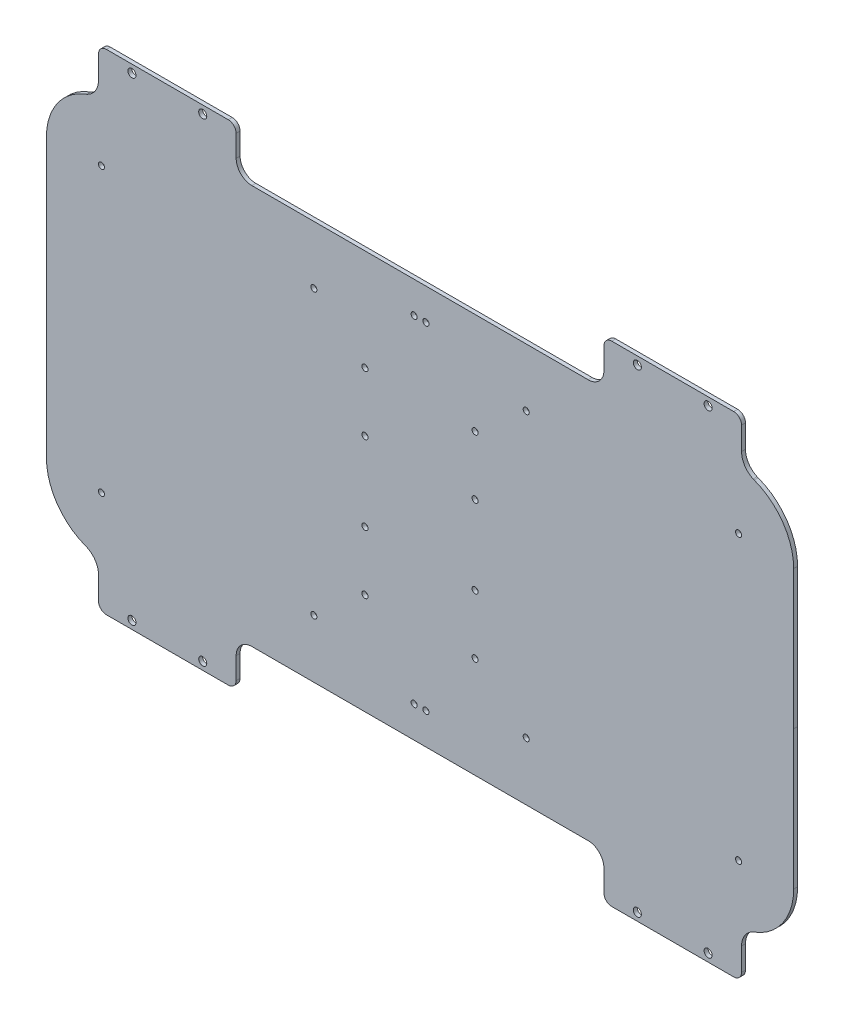
from build123d import *

# Parameters (mm, degrees)
SKETCH1_R           = 2.05
SKETCH1_R_2         = 1.55
BOSS_EXTRUDE1_DEPTH = 2
FILLET_1_R          = 10
FILLET_2_R          = 3
EXTRUDE_1_DEPTH     = 2
CUT_EXTRUDE_1_DEPTH = 10
FILLET_3_R          = 4
SKETCH5_R           = 1.55
CUT_EXTRUDE1_DEPTH  = 10


with BuildPart() as part:
    # Sketch1 → Boss-Extrude1 (new body)
    with BuildSketch(Plane.XY):
        Polygon((-89.5, -124.5), (-89.5, -101.5), (89.5, -101.5), (89.5, -124.5), (167.5, -124.5), (167.5, 124.5), (89.5, 124.5), (89.5, 101.5), (-89.5, 101.5), (-89.5, 124.5), (-167.5, 124.5), (-167.5, -124.5), align=None)
        with Locations((-146.5, -120.5)):
            Circle(SKETCH1_R, mode=Mode.SUBTRACT)
        with Locations((-110.5, -120.5)):
            Circle(SKETCH1_R, mode=Mode.SUBTRACT)
        with Locations((110.5, -120.5)):
            Circle(SKETCH1_R, mode=Mode.SUBTRACT)
        with Locations((146.5, -120.5)):
            Circle(SKETCH1_R, mode=Mode.SUBTRACT)
        with Locations((110.5, 120.5)):
            Circle(SKETCH1_R, mode=Mode.SUBTRACT)
        with Locations((146.5, 120.5)):
            Circle(SKETCH1_R, mode=Mode.SUBTRACT)
        with Locations((-110.5, 120.5)):
            Circle(SKETCH1_R, mode=Mode.SUBTRACT)
        with Locations((-146.5, 120.5)):
            Circle(SKETCH1_R, mode=Mode.SUBTRACT)
        with Locations((-28, -50)):
            Circle(SKETCH1_R_2, mode=Mode.SUBTRACT)
        with Locations((-28, -20)):
            Circle(SKETCH1_R_2, mode=Mode.SUBTRACT)
        with Locations((-28, 20)):
            Circle(SKETCH1_R_2, mode=Mode.SUBTRACT)
        with Locations((-28, 50)):
            Circle(SKETCH1_R_2, mode=Mode.SUBTRACT)
        with Locations((28, 50)):
            Circle(SKETCH1_R_2, mode=Mode.SUBTRACT)
        with Locations((28, 20)):
            Circle(SKETCH1_R_2, mode=Mode.SUBTRACT)
        with Locations((28, -20)):
            Circle(SKETCH1_R_2, mode=Mode.SUBTRACT)
        with Locations((28, -50)):
            Circle(SKETCH1_R_2, mode=Mode.SUBTRACT)
        with Locations((-162, -72)):
            Circle(SKETCH1_R_2, mode=Mode.SUBTRACT)
        with Locations((-54, -72)):
            Circle(SKETCH1_R_2, mode=Mode.SUBTRACT)
        with Locations((-162, 72)):
            Circle(SKETCH1_R_2, mode=Mode.SUBTRACT)
        with Locations((-54, 72)):
            Circle(SKETCH1_R_2, mode=Mode.SUBTRACT)
        with Locations((162, 72)):
            Circle(SKETCH1_R_2, mode=Mode.SUBTRACT)
        with Locations((54, 72)):
            Circle(SKETCH1_R_2, mode=Mode.SUBTRACT)
        with Locations((162, -72)):
            Circle(SKETCH1_R_2, mode=Mode.SUBTRACT)
        with Locations((54, -72)):
            Circle(SKETCH1_R_2, mode=Mode.SUBTRACT)
    extrude(amount=BOSS_EXTRUDE1_DEPTH)

    # 圆角1
    fillet_1_edges = [part.edges().sort_by_distance(p)[0] for p in [
        (-89.5, 101.5, 1),
        (89.5, 101.5, 1),
        (89.5, -101.5, 1),
        (-89.5, -101.5, 1),
    ]]
    fillet(fillet_1_edges, radius=FILLET_1_R)

    # 圆角2
    fillet_2_edges = [part.edges().sort_by_distance(p)[0] for p in [
        (89.5, 124.5, 1),
        (167.5, 124.5, 1),
        (167.5, -124.5, 1),
        (89.5, -124.5, 1),
        (-89.5, -124.5, 1),
        (-167.5, -124.5, 1),
        (-167.5, 124.5, 1),
        (-89.5, 124.5, 1),
    ]]
    fillet(fillet_2_edges, radius=FILLET_2_R)

    # 草图1 → 凸台-拉伸1 (add)
    with BuildSketch(Plane.XY.offset(2)):
        with BuildLine():
            Line((189.997376171, 0), (189.999999808, 70.585935638))
            ThreePointArc((189.999999808, 70.585935638), (184.491557968, 88.202366102), (169.927835286, 99.541657768))
            ThreePointArc((169.927835286, 99.541657768), (167.242378396, 101.21624095), (165.416431352, 103.801163566))
            Line((165.416431352, 103.801163566), (165.416428605, 0))
            Line((165.416428605, 0), (165.416431352, -103.801163566))
            ThreePointArc((165.416431352, -103.801163566), (167.242378396, -101.21624095), (169.927835286, -99.541657768))
            ThreePointArc((169.927835286, -99.541657768), (184.491557968, -88.202366102), (189.999999808, -70.585935638))
            Line((189.999999808, -70.585935638), (189.997376171, 0))
        make_face()
        with BuildLine():
            Line((-165.416431352, 103.801163566), (-165.416428605, 0))
            Line((-165.416428605, 0), (-165.416431352, -103.801163566))
            ThreePointArc((-165.416431352, -103.801163566), (-167.242378396, -101.21624095), (-169.927835286, -99.541657768))
            ThreePointArc((-169.927835286, -99.541657768), (-184.491557968, -88.202366102), (-189.999999808, -70.585935638))
            Line((-189.999999808, -70.585935638), (-189.997376171, 0))
            Line((-189.997376171, 0), (-189.999999808, 70.585935638))
            ThreePointArc((-189.999999808, 70.585935638), (-184.491557968, 88.202366102), (-169.927835286, 99.541657768))
            ThreePointArc((-169.927835286, 99.541657768), (-167.242378396, 101.21624095), (-165.416431352, 103.801163566))
        make_face()
    extrude(amount=-EXTRUDE_1_DEPTH)

    # 草图2 → 切除-拉伸1 (cut)
    with BuildSketch(Plane(origin=(0, 0, 0), x_dir=(-1, 0, 0), z_dir=(0, 0, -1))):
        with BuildLine():
            Line((-163.5, 108.882062038), (-163.5, 125.12763211))
            Line((-163.5, 125.12763211), (-195.489977478, 125.12763211))
            Line((-195.489977478, 125.12763211), (-189.999999808, 70.585935638))
            ThreePointArc((-189.999999808, 70.585935638), (-184.506224613, 88.181189445), (-169.976064889, 99.523542853))
            ThreePointArc((-169.976064889, 99.523542853), (-165.276881641, 103.191690833), (-163.5, 108.882062038))
        make_face()
        with BuildLine():
            Line((-60.806736633, 101.5), (-85.5, 101.5))
            ThreePointArc((-85.5, 101.5), (-91.156854249, 103.843145751), (-93.5, 109.5))
            Line((-93.5, 109.5), (-93.5, 125.12763211))
            Line((-93.5, 125.12763211), (-60.806736633, 125.12763211))
            Line((-60.806736633, 125.12763211), (-60.806736633, 101.5))
        make_face()
        with BuildLine():
            Line((60.806736633, 125.12763211), (60.806736633, 101.5))
            Line((60.806736633, 101.5), (85.5, 101.5))
            ThreePointArc((85.5, 101.5), (91.156854249, 103.843145751), (93.5, 109.5))
            Line((93.5, 109.5), (93.5, 125.12763211))
            Line((93.5, 125.12763211), (60.806736633, 125.12763211))
        make_face()
        with BuildLine():
            Line((195.489977478, 125.12763211), (189.999999808, 70.585935638))
            ThreePointArc((189.999999808, 70.585935638), (184.506224613, 88.181189445), (169.976064889, 99.523542853))
            ThreePointArc((169.976064889, 99.523542853), (165.276881641, 103.191690833), (163.5, 108.882062038))
            Line((163.5, 108.882062038), (163.5, 125.12763211))
            Line((163.5, 125.12763211), (195.489977478, 125.12763211))
        make_face()
        with BuildLine():
            Line((163.5, -108.882062038), (163.5, -125.12763211))
            Line((163.5, -125.12763211), (195.489977478, -125.12763211))
            Line((195.489977478, -125.12763211), (189.999999808, -70.585935638))
            ThreePointArc((189.999999808, -70.585935638), (184.506224613, -88.181189445), (169.976064889, -99.523542853))
            ThreePointArc((169.976064889, -99.523542853), (165.276881641, -103.191690833), (163.5, -108.882062038))
        make_face()
        with BuildLine():
            Line((60.806736633, -101.5), (85.5, -101.5))
            ThreePointArc((85.5, -101.5), (91.156854249, -103.843145751), (93.5, -109.5))
            Line((93.5, -109.5), (93.5, -125.12763211))
            Line((93.5, -125.12763211), (60.806736633, -125.12763211))
            Line((60.806736633, -125.12763211), (60.806736633, -101.5))
        make_face()
        with BuildLine():
            Line((-60.806736633, -125.12763211), (-60.806736633, -101.5))
            Line((-60.806736633, -101.5), (-85.5, -101.5))
            ThreePointArc((-85.5, -101.5), (-91.156854249, -103.843145751), (-93.5, -109.5))
            Line((-93.5, -109.5), (-93.5, -125.12763211))
            Line((-93.5, -125.12763211), (-60.806736633, -125.12763211))
        make_face()
        with BuildLine():
            Line((-195.489977478, -125.12763211), (-189.999999808, -70.585935638))
            ThreePointArc((-189.999999808, -70.585935638), (-184.506224613, -88.181189445), (-169.976064889, -99.523542853))
            ThreePointArc((-169.976064889, -99.523542853), (-165.276881641, -103.191690833), (-163.5, -108.882062038))
            Line((-163.5, -108.882062038), (-163.5, -125.12763211))
            Line((-163.5, -125.12763211), (-195.489977478, -125.12763211))
        make_face()
    extrude(amount=-CUT_EXTRUDE_1_DEPTH, mode=Mode.SUBTRACT)

    # 圆角3
    fillet_3_edges = [part.edges().sort_by_distance(p)[0] for p in [
        (93.5, 124.5, 1),
        (-93.5, 124.5, 1),
        (-163.5, 124.5, 1),
        (-163.5, -124.5, 1),
        (-93.5, -124.5, 1),
        (93.5, -124.5, 1),
        (163.5, -124.5, 1),
        (163.5, 124.5, 1),
    ]]
    fillet(fillet_3_edges, radius=FILLET_3_R)

    # Sketch5 → Cut-Extrude1 (cut)
    with BuildSketch(Plane(origin=(0, 0, 0), x_dir=(-1, 0, 0), z_dir=(0, 0, -1))):
        with Locations((3, 85.5)):
            Circle(SKETCH5_R)
        with Locations((-3, 85.5)):
            Circle(SKETCH5_R)
        with Locations((-3, -85.5)):
            Circle(SKETCH5_R)
        with Locations((3, -85.5)):
            Circle(SKETCH5_R)
    extrude(amount=-CUT_EXTRUDE1_DEPTH, mode=Mode.SUBTRACT)


solid = part.part
